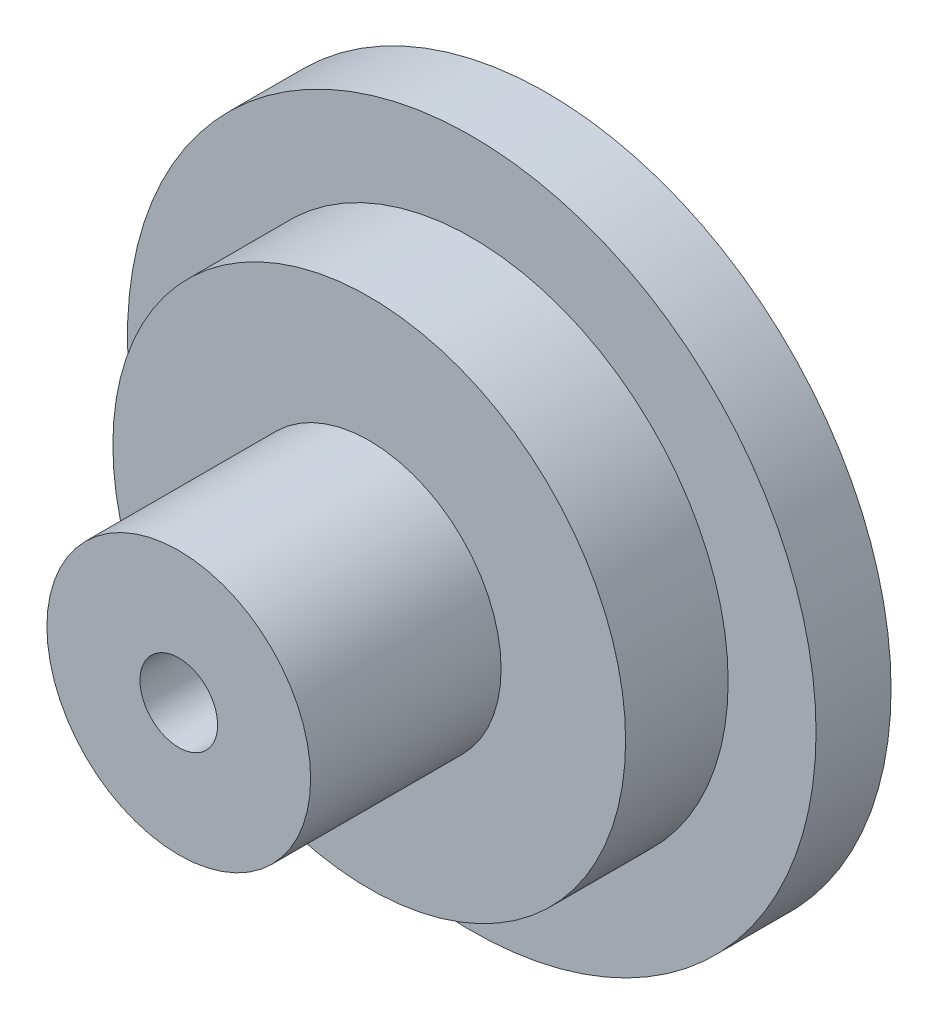
from build123d import *

# Parameters (mm, degrees)
SKETCH1_R                     = 23.5
BOSS_EXTRUDE1_DEPTH           = 5.12
SKETCH2_R                     = 17.5
BOSS_EXTRUDE2_DEPTH           = 7
SKETCH3_R                     = 9
BOSS_EXTRUDE3_DEPTH           = 13
CSK_FOR_M5_SFHCS1_D           = 5.3
CSK_FOR_M5_SFHCS1_CSINK_D     = 11.2
CSK_FOR_M5_SFHCS1_CSINK_ANGLE = 90


with BuildPart() as part:
    # Sketch1 → Boss-Extrude1 (new body)
    with BuildSketch(Plane.XY):
        Circle(SKETCH1_R)
    extrude(amount=BOSS_EXTRUDE1_DEPTH)

    # Sketch2 → Boss-Extrude2 (add)
    with BuildSketch(Plane.XY.offset(5.12)):
        Circle(SKETCH2_R)
    extrude(amount=BOSS_EXTRUDE2_DEPTH)

    # Sketch3 → Boss-Extrude3 (add)
    with BuildSketch(Plane.XY.offset(12.12)):
        Circle(SKETCH3_R)
    extrude(amount=BOSS_EXTRUDE3_DEPTH)

    # CSK for M5 SFHCS1 (through all)
    with Locations(Plane(origin=(0, 0, 0), x_dir=(-1, 0, 0), z_dir=(0, 0, -1))):
        with Locations((0, 0)):
            CounterSinkHole(CSK_FOR_M5_SFHCS1_D / 2, CSK_FOR_M5_SFHCS1_CSINK_D / 2, counter_sink_angle=CSK_FOR_M5_SFHCS1_CSINK_ANGLE)


solid = part.part
